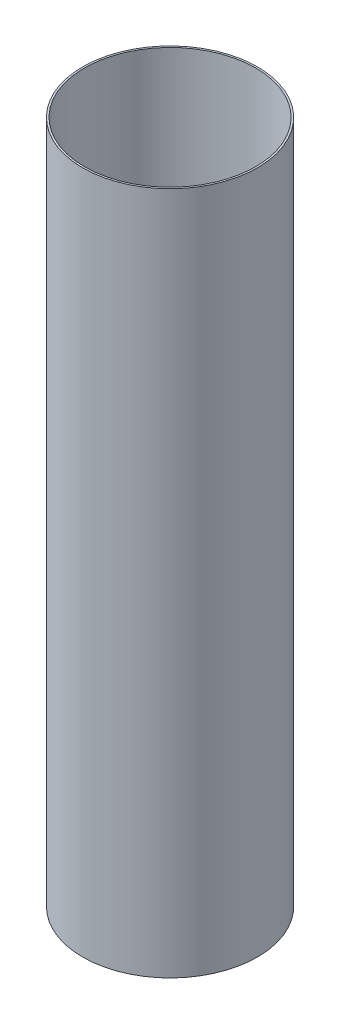
from build123d import *

# Parameters (mm, degrees)
SKETCH1_R           = 97.4725
SKETCH1_R_2         = 95.4405
BOSS_EXTRUDE1_DEPTH = 762


with BuildPart() as part:
    # Sketch1 → Boss-Extrude1 (new body)
    with BuildSketch(Plane(origin=(0, 0, 0), x_dir=(1, 0, 0), z_dir=(0, 1, 0))):
        Circle(SKETCH1_R)
        Circle(SKETCH1_R_2, mode=Mode.SUBTRACT)
    extrude(amount=BOSS_EXTRUDE1_DEPTH)


solid = part.part
